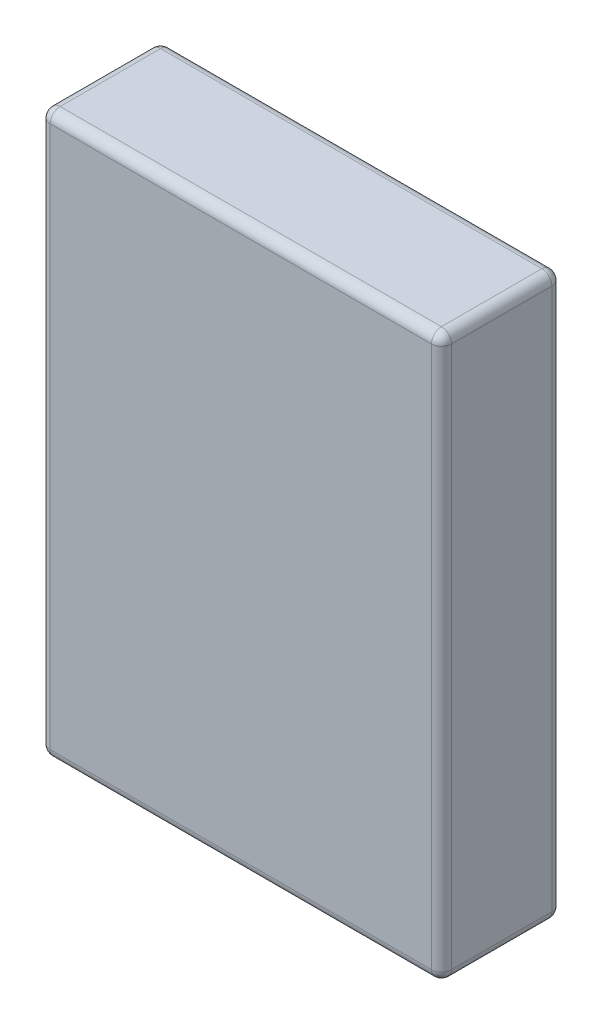
from build123d import *

# Parameters (mm, degrees)
SKETCH1_W           = 127
SKETCH1_H           = 177.8
BOSS_EXTRUDE1_DEPTH = 38.1
FILLET1_R           = 3.175


with BuildPart() as part:
    # Sketch1 → Boss-Extrude1 (new body)
    with BuildSketch(Plane.XY):
        Rectangle(SKETCH1_W, SKETCH1_H)
    extrude(amount=BOSS_EXTRUDE1_DEPTH)

    # Fillet1
    fillet1_edges = [part.edges().sort_by_distance(p)[0] for p in [
        (-63.5, 0, 38.1),
        (0, -88.9, 38.1),
        (63.5, 0, 38.1),
        (0, -88.9, 0),
        (-63.5, 0, 0),
        (0, 88.9, 0),
        (63.5, 0, 0),
        (0, 88.9, 38.1),
        (63.5, -88.9, 19.05),
        (-63.5, -88.9, 19.05),
        (-63.5, 88.9, 19.05),
        (63.5, 88.9, 19.05),
    ]]
    fillet(fillet1_edges, radius=FILLET1_R)


solid = part.part
